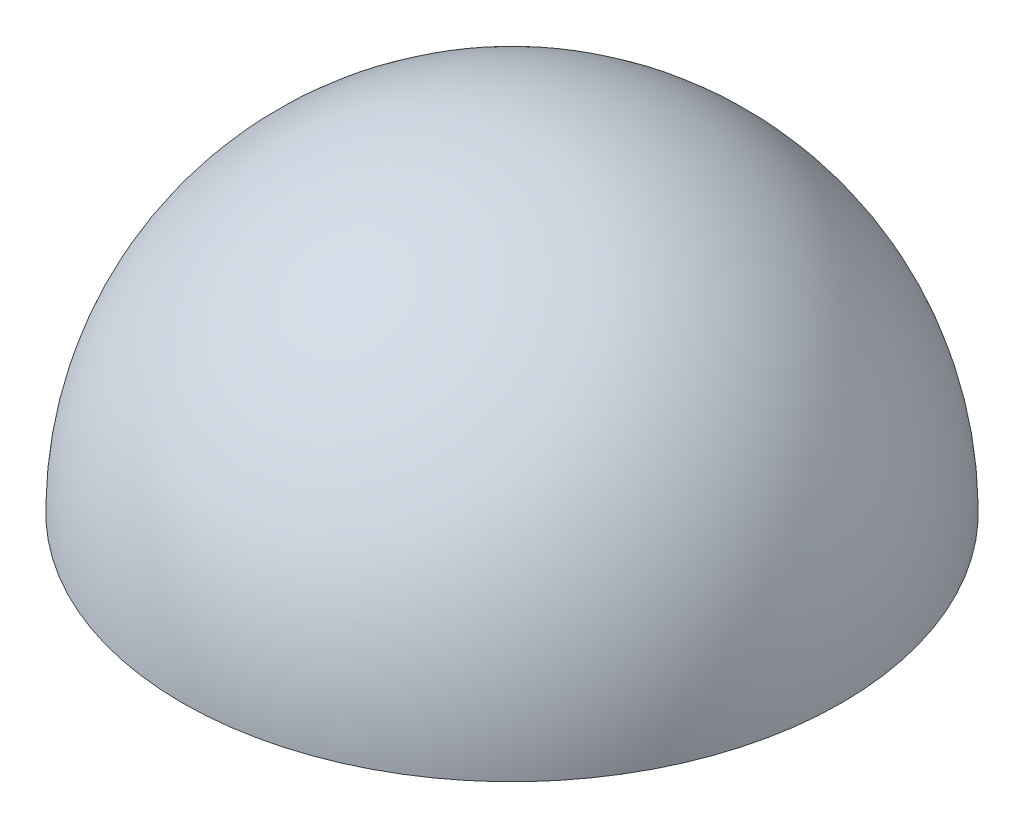
from build123d import *


with BuildPart() as part:
    # Sketch1 → Revolve1 (revolve)
    with BuildSketch(Plane.XY):
        with BuildLine():
            Line((0, 1.5), (0, 0))
            Line((0, 0), (1.5, 0))
            ThreePointArc((1.5, 0), (1.060660172, 1.060660172), (0, 1.5))
        make_face()
    revolve(axis=Axis((0, 1.5, 0), (0, -1, 0)))


solid = part.part
